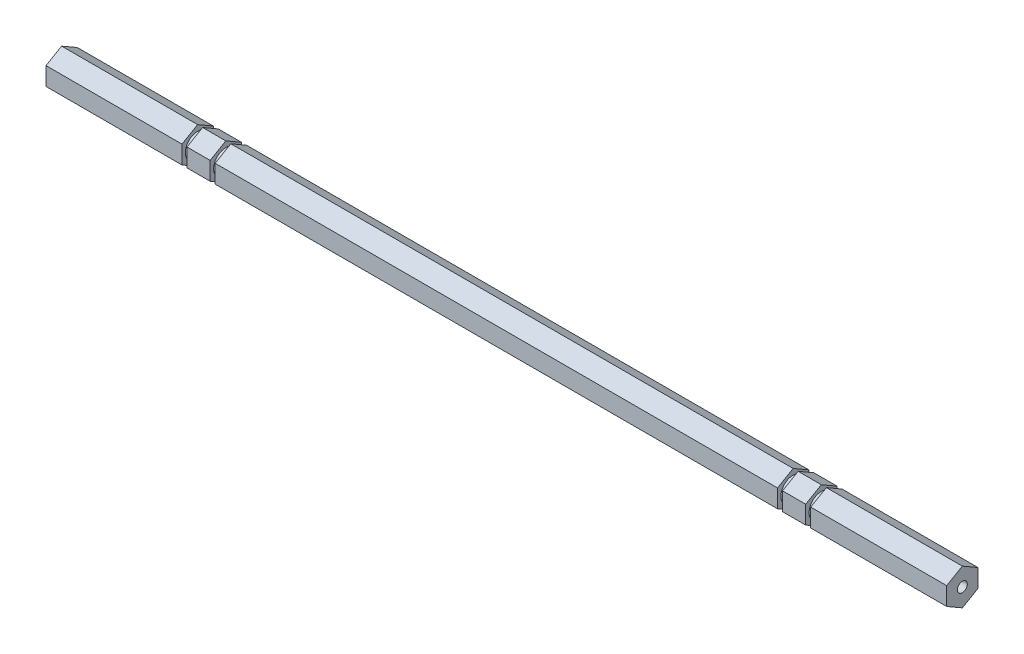
from build123d import *

# Parameters (mm, degrees)
BOSS_EXTRUDE1_DEPTH        = 365.125
F_10_32_TAPPED_HOLE1_D     = 4.0386
F_10_32_TAPPED_HOLE1_DEPTH = 12.0396
F_10_32_TAPPED_HOLE1_TIP   = 1.213317848
F_10_32_TAPPED_HOLE2_D     = 4.0386
F_10_32_TAPPED_HOLE2_DEPTH = 12.0396
F_10_32_TAPPED_HOLE2_TIP   = 1.213317848
SKETCH6_W                  = 2.032
SKETCH6_H                  = 2.353948419


with BuildPart() as part:
    # Sketch1 → Boss-Extrude1 (new body)
    with BuildSketch(Plane(origin=(0, 0, 0), x_dir=(0, 0, -1), z_dir=(1, 0, 0))):
        Polygon((0, 7.332348419), (-6.35, 3.666174209), (-6.35, -3.666174209), (0, -7.332348419), (6.35, -3.666174209), (6.35, 3.666174209), align=None)
    extrude(amount=BOSS_EXTRUDE1_DEPTH)

    # 10-32 Tapped Hole1
    with Locations(Plane(origin=(365.125, 0, 0), x_dir=(0, 0, -1), z_dir=(1, 0, 0))):
        with Locations((0, 0)):
            Hole(F_10_32_TAPPED_HOLE1_D / 2, depth=F_10_32_TAPPED_HOLE1_DEPTH)
            with Locations((0, 0, -(F_10_32_TAPPED_HOLE1_DEPTH + F_10_32_TAPPED_HOLE1_TIP / 2))):  # 118° drill point
                Cone(0, F_10_32_TAPPED_HOLE1_D / 2, F_10_32_TAPPED_HOLE1_TIP, mode=Mode.SUBTRACT)

    # 10-32 Tapped Hole2
    with Locations(Plane.ZY):
        with Locations((0, 0)):
            Hole(F_10_32_TAPPED_HOLE2_D / 2, depth=F_10_32_TAPPED_HOLE2_DEPTH)
            with Locations((0, 0, -(F_10_32_TAPPED_HOLE2_DEPTH + F_10_32_TAPPED_HOLE2_TIP / 2))):  # 118° drill point
                Cone(0, F_10_32_TAPPED_HOLE2_D / 2, F_10_32_TAPPED_HOLE2_TIP, mode=Mode.SUBTRACT)

    # Sketch6 → Cut-Revolve1 (revolve, cut)
    with BuildSketch(Plane.XY):
        with Locations((56.134, 6.15537421)):
            Rectangle(SKETCH6_W, SKETCH6_H)
        with Locations((67.564, 6.15537421)):
            Rectangle(SKETCH6_W, SKETCH6_H)
        with Locations((297.561, 6.15537421)):
            Rectangle(SKETCH6_W, SKETCH6_H)
        with Locations((308.991, 6.15537421)):
            Rectangle(SKETCH6_W, SKETCH6_H)
    revolve(axis=Axis((0, 0, 0), (1, 0, 0)), mode=Mode.SUBTRACT)


solid = part.part
